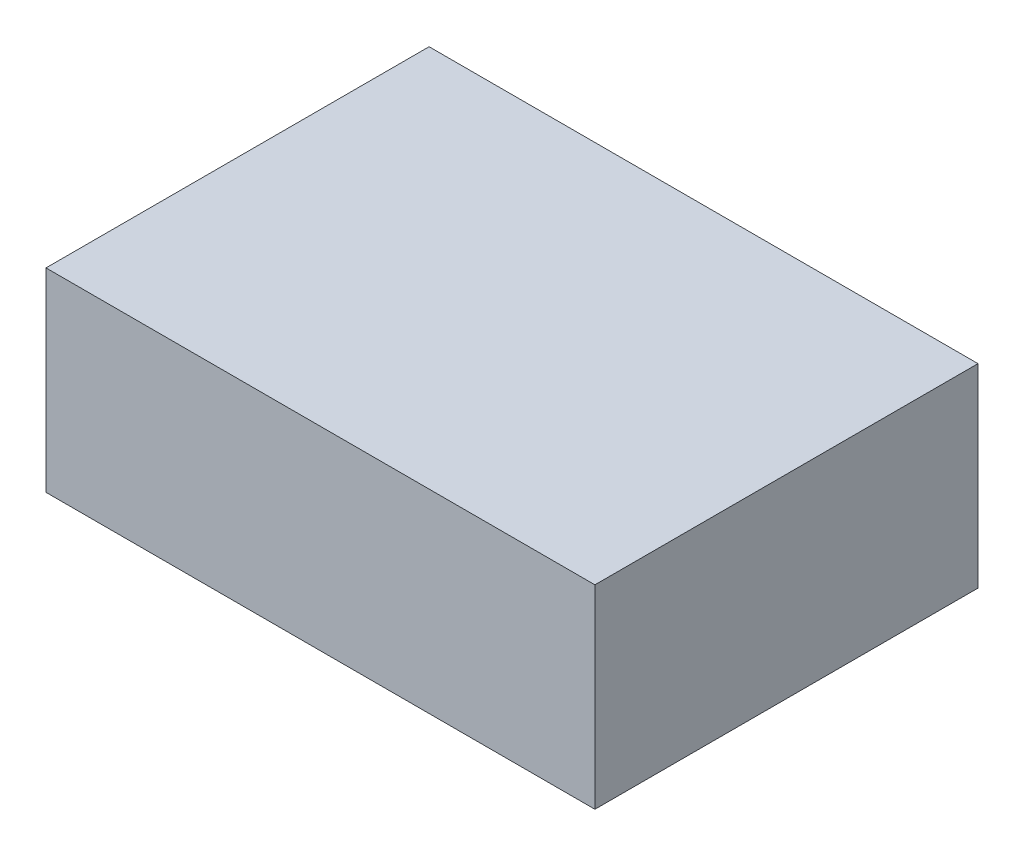
from build123d import *

# Parameters (mm, degrees)
SKETCH2_W           = 96
SKETCH2_H           = 67
BOSS_EXTRUDE1_DEPTH = 34


with BuildPart() as part:
    # Sketch2 → Boss-Extrude1 (new body)
    with BuildSketch(Plane(origin=(0, 0, 0), x_dir=(1, 0, 0), z_dir=(0, 1, 0))):
        Rectangle(SKETCH2_W, SKETCH2_H)
    extrude(amount=BOSS_EXTRUDE1_DEPTH)


solid = part.part
